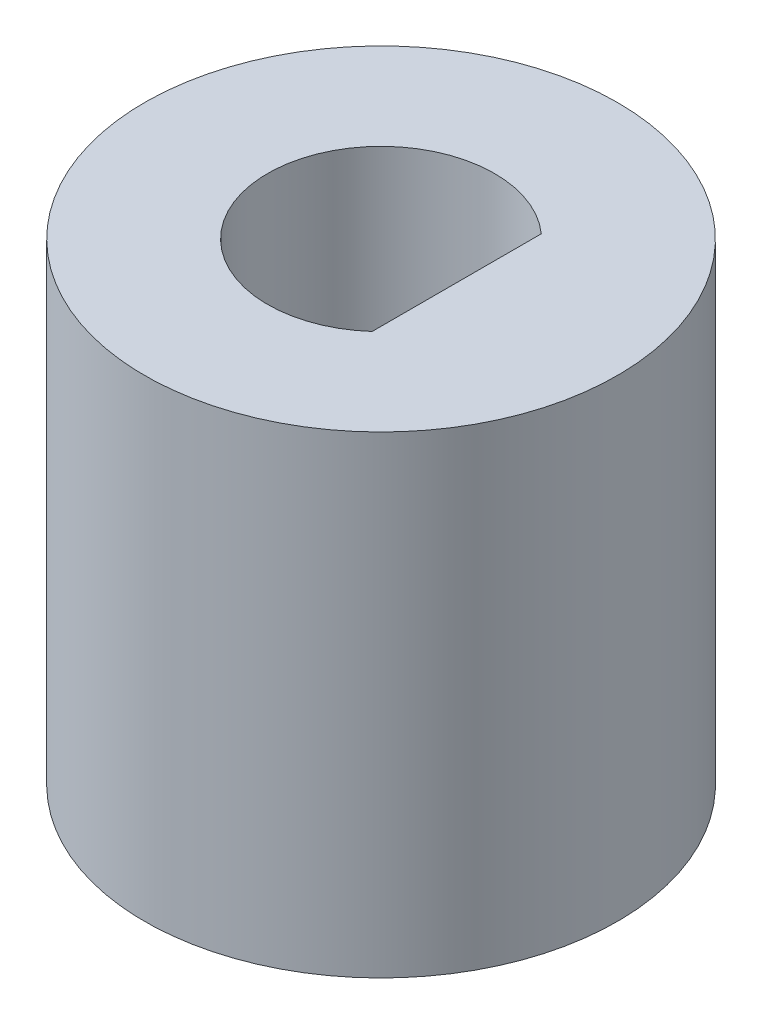
from build123d import *

# Parameters (mm, degrees)
CORTE_EXTRUS_O1_DEPTH    = 5
ESBO_O3_W                = 2.513225657
ESBO_O3_H                = 5.478331089
RESSALTO_EXTRUS_O1_DEPTH = 5


with BuildPart() as part:
    # Esboço1 → Revolução1 (revolve)
    with BuildSketch(Plane.XY):
        Polygon((-1, 10), (-5, 10), (-5, 0), (-2, 0), (-2, 5), (-1, 5), align=None)
    revolve(axis=Axis((0, 0, 0), (0, 1, 0)))

    # Esboço2 → Corte-extrusão1 (cut)
    with BuildSketch(Plane(origin=(0, 10, 0), x_dir=(1, 0, 0), z_dir=(0, 1, 0))):
        with BuildLine():
            Line((1.6, 1.788854382), (1.6, -1.788854382))
            ThreePointArc((1.6, -1.788854382), (-2.4, 0), (1.6, 1.788854382))
        make_face()
    extrude(amount=-CORTE_EXTRUS_O1_DEPTH, mode=Mode.SUBTRACT)

    # Esboço3 → Ressalto-extrusão1 (add)
    with BuildSketch(Plane.XZ):
        with Locations((1.756612829, -0.034046623)):
            Rectangle(ESBO_O3_W, ESBO_O3_H)
    extrude(amount=-RESSALTO_EXTRUS_O1_DEPTH)


solid = part.part
